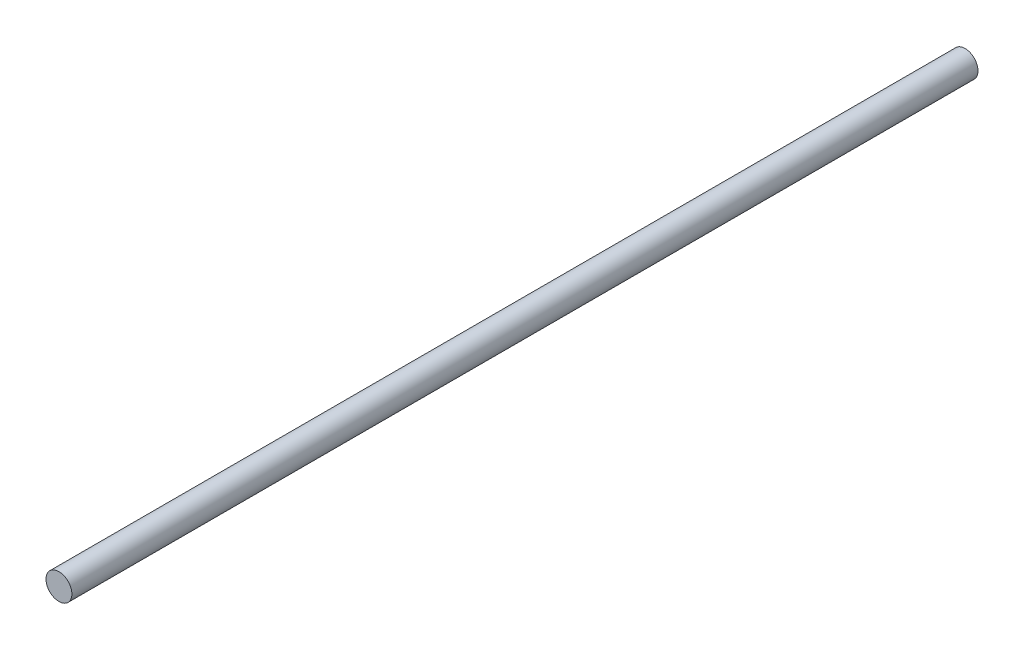
from build123d import *

# Parameters (mm, degrees)
ESBO_O1_R                = 6
RESSALTO_EXTRUS_O1_DEPTH = 420


with BuildPart() as part:
    # Esboço1 → Ressalto-extrusão1 (new body)
    with BuildSketch(Plane.XY):
        Circle(ESBO_O1_R)
    extrude(amount=RESSALTO_EXTRUS_O1_DEPTH)


solid = part.part
